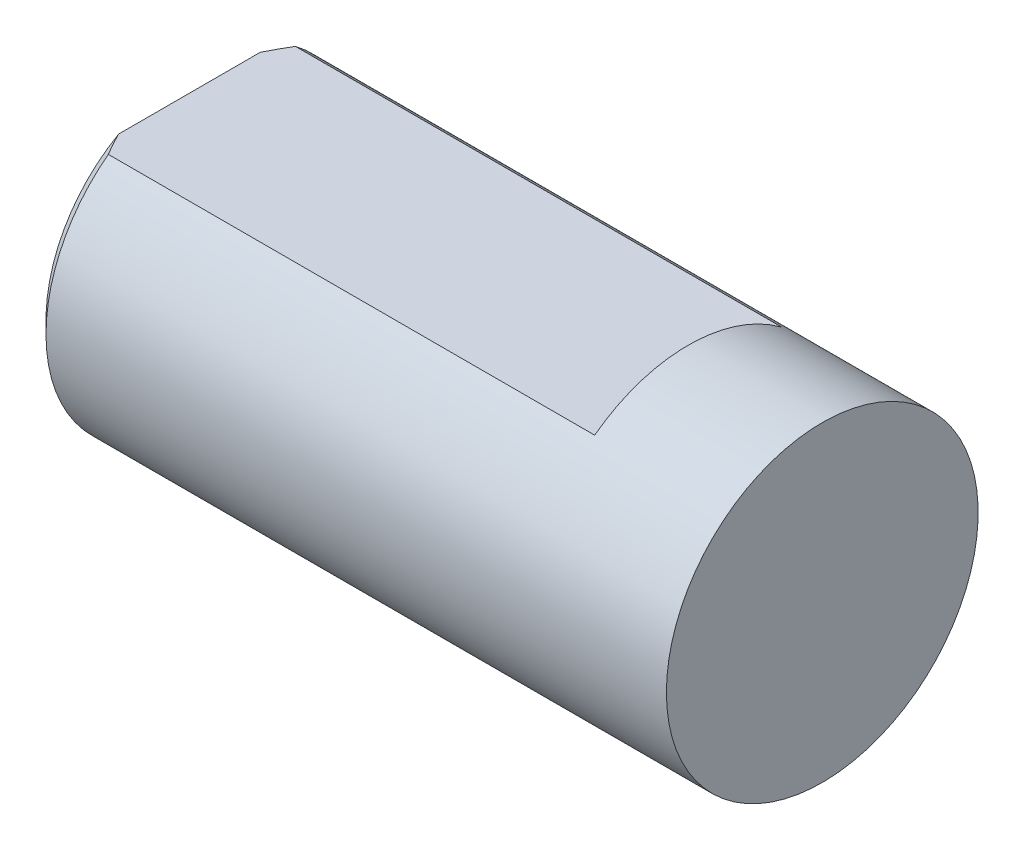
from build123d import *

# Parameters (mm, degrees)
ESQUISSE1_W             = 10.15
ESQUISSE1_H             = 2.5
ENL_V_MAT_EXTRU_1_DEPTH = 8
CHANFREIN1_SIZE         = 0.2


with BuildPart() as part:
    # Esquisse1 → Révolution1 (revolve)
    with BuildSketch(Plane.XY, mode=Mode.PRIVATE) as r_volution1_sk:
        with Locations((-5.075, 1.25)):
            Rectangle(ESQUISSE1_W, ESQUISSE1_H)
    revolve(r_volution1_sk.sketch.rotate(Axis((0, 0, 0), (1, 0, 0)), 90), axis=Axis((0, 0, 0), (1, 0, 0)))  # turned: the seam where the file's is

    # Esquisse2 → Enlèv. mat.-Extru.1 (cut)
    with BuildSketch(Plane.ZY.offset(10.15)):
        with BuildLine():
            Line((-1.5, 2), (0, 2))
            Line((0, 2), (1.5, 2))
            ThreePointArc((1.5, 2), (0, 2.5), (-1.5, 2))
        make_face()
    extrude(amount=-ENL_V_MAT_EXTRU_1_DEPTH, mode=Mode.SUBTRACT)

    # Chanfrein1
    chanfrein1_edges = [part.edges().sort_by_distance(p)[0] for p in [
        (-10.15, -2.236067977, -1.118033989),
    ]]
    chamfer(chanfrein1_edges, length=CHANFREIN1_SIZE)


solid = part.part
